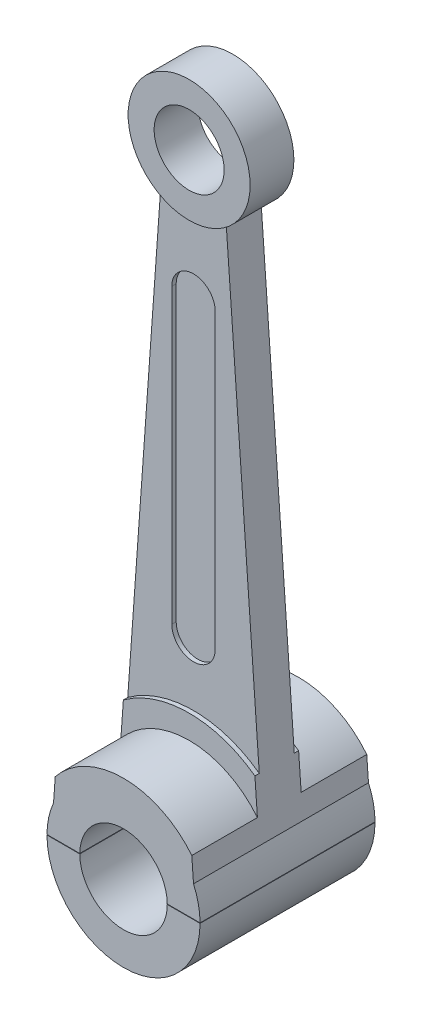
from build123d import *

# Parameters (mm, degrees)
SKETCH1_R                = 1.395
SKETCH1_R_2              = 0.8
BOSS_EXTRUDE1_DEPTH      = 0.5
SKETCH1_R_3              = 2.54
SKETCH1_R_4              = 1
BOSS_EXTRUDE1_2_DEPTH    = 0.5
BOSS_EXTRUDE2_DEPTH      = 0.4
BOSS_EXTRUDE3_DEPTH      = 0.3
BOSS_EXTRUDE4_DEPTH      = 1.5
BOSS_EXTRUDE4_DEPTH_BACK = 2.5
SKETCH2_R                = 2
SKETCH2_R_2              = 1
CUT_EXTRUDE1_DEPTH       = 15.75
SKETCH4_W                = 11.932822614
SKETCH4_H                = 0.01
CUT_EXTRUDE2_DEPTH       = 15.75


with BuildPart() as part:
    # Sketch1 → Boss-Extrude1 (new, symmetric)
    with BuildSketch(Plane.XY):
        with Locations((0, 13.69)):
            Circle(SKETCH1_R)
        with Locations((0, 13.69)):
            Circle(SKETCH1_R_2, mode=Mode.SUBTRACT)
    extrude(amount=BOSS_EXTRUDE1_DEPTH, both=True)



with BuildPart() as body_2:
    # Sketch1 → Boss-Extrude1 2 (new, symmetric)
    with BuildSketch(Plane.XY):
        Circle(SKETCH1_R_3)
        Circle(SKETCH1_R_4, mode=Mode.SUBTRACT)
    extrude(amount=BOSS_EXTRUDE1_2_DEPTH, both=True)


with BuildPart() as part_1:
    add(part.part)

    add(body_2.part)  # Boss-Extrude2 merges body 2
    # Sketch1_3 → Boss-Extrude2 (add, symmetric)
    with BuildSketch(Plane.XY):
        with BuildLine():
            ThreePointArc((0.75, 12.513766605), (0, 12.295), (-0.75, 12.513766605))
            Line((-0.75, 12.513766605), (-1.65, 1.931087776))
            ThreePointArc((-1.65, 1.931087776), (0, 2.54), (1.65, 1.931087776))
            Line((1.65, 1.931087776), (0.75, 12.513766605))
        make_face()
        with BuildLine():
            ThreePointArc((-0.496250448, 10.69), (0, 11.186250448), (0.496250448, 10.69))
            Line((0.496250448, 10.69), (0.496250448, 4))
            ThreePointArc((0.496250448, 4), (0, 3.503749552), (-0.496250448, 4))
            Line((-0.496250448, 4), (-0.496250448, 10.69))
        make_face(mode=Mode.SUBTRACT)
    extrude(amount=BOSS_EXTRUDE2_DEPTH, both=True)

    # Sketch1_4 → Boss-Extrude3 (add, symmetric)
    with BuildSketch(Plane.XY):
        with BuildLine():
            Line((0.496250448, 4), (0.496250448, 10.69))
            ThreePointArc((0.496250448, 10.69), (0, 11.186250448), (-0.496250448, 10.69))
            Line((-0.496250448, 10.69), (-0.496250448, 4))
            ThreePointArc((-0.496250448, 4), (0, 3.503749552), (0.496250448, 4))
        make_face()
    extrude(amount=BOSS_EXTRUDE3_DEPTH, both=True)

    # Sketch2 → Boss-Extrude4 (add, two sides: drawn at the far end of the back side and taken through both)
    with BuildSketch(Plane.XY.offset(0.5).offset(-BOSS_EXTRUDE4_DEPTH_BACK)):
        Circle(SKETCH2_R)
        Circle(SKETCH2_R_2, mode=Mode.SUBTRACT)
    extrude(amount=BOSS_EXTRUDE4_DEPTH + BOSS_EXTRUDE4_DEPTH_BACK)

    # Sketch3 → Cut-Extrude1 (cut, symmetric)
    with BuildSketch(Plane.XY):
        with BuildLine():
            Line((-2.441497921, 2.507805395), (-0.75, 12.513766605))
            Line((-0.75, 12.513766605), (-1.6, 0.708872344))
            ThreePointArc((-1.6, 0.708872344), (0, -1.75), (1.6, 0.708872344))
            Line((1.6, 0.708872344), (0.75, 12.513766605))
            Line((0.75, 12.513766605), (2.441497921, 2.507805395))
            ThreePointArc((2.441497921, 2.507805395), (0, -3.5), (-2.441497921, 2.507805395))
        make_face()
    extrude(amount=CUT_EXTRUDE1_DEPTH, both=True, mode=Mode.SUBTRACT)

    # Sketch4 → Cut-Extrude2 (cut, symmetric)
    with BuildSketch(Plane.XY):
        with Locations((1.140460914, 0.005)):
            Rectangle(SKETCH4_W, SKETCH4_H)
    extrude(amount=CUT_EXTRUDE2_DEPTH, both=True, mode=Mode.SUBTRACT)


with BuildPart() as cut_extrude2_piece_1:
    # of the separate pieces the step leaves, piece 1, a body of its own (cut_extrude2_pieces)
    add(part_1.part.solids().sort_by_distance((1.503641437, 2.047110751, -0.5))[0])


with BuildPart() as cut_extrude2_piece_2:
    # of the separate pieces the step leaves, piece 2, a body of its own (cut_extrude2_pieces)
    add(part_1.part.solids().sort_by_distance((-1.75, 0, 2))[0])


solid = Compound([cut_extrude2_piece_1.part, cut_extrude2_piece_2.part])
